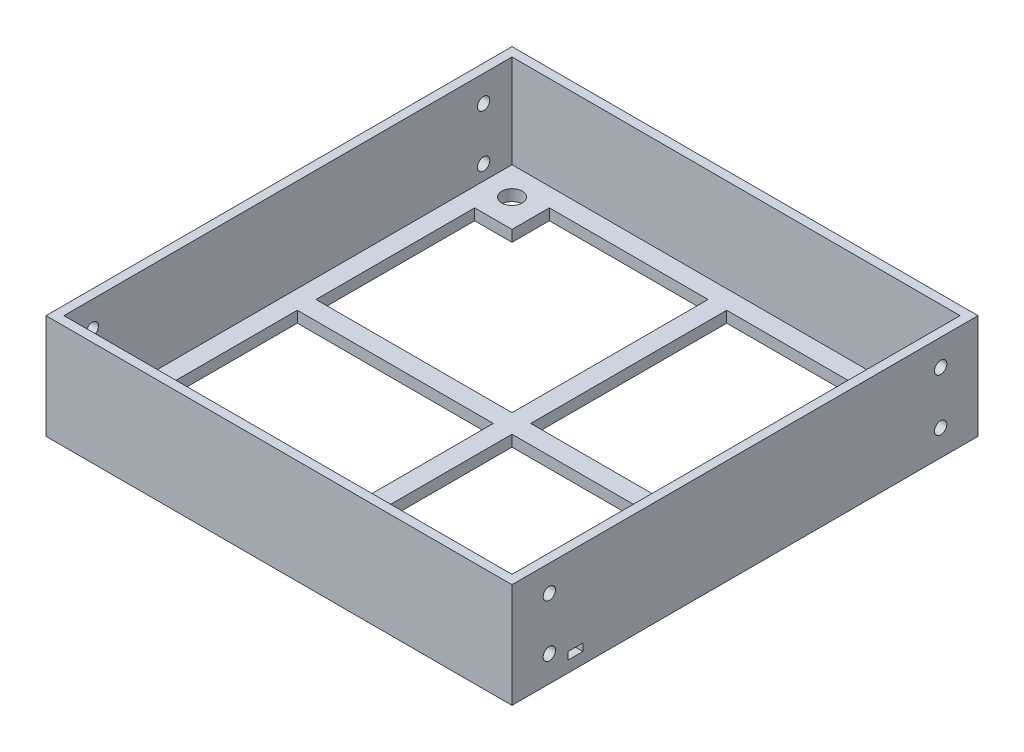
from build123d import *

# Parameters (mm, degrees)
SKETCH1_W                      = 120
SKETCH1_H                      = 120
BOSS_EXTRUDE1_DEPTH            = 3
CUT_EXTRUDE1_REACH             = 5
CUT_EXTRUDE1_DIRECTION_2_DEPTH = 1
CUT_EXTRUDE2_REACH             = 5
SKETCH3_R                      = 2.75
SKETCH5_W                      = 124.8
SKETCH5_H                      = 124.8
SKETCH5_W_2                    = 120
SKETCH5_H_2                    = 120
BOSS_EXTRUDE2_DEPTH            = 28
SKETCH6_R                      = 1.65
CUT_EXTRUDE3_DEPTH             = 125.8
SKETCH7_W                      = 4
SKETCH7_H                      = 2
CUT_EXTRUDE4_DEPTH             = 125.8


with BuildPart() as part:
    # Sketch1 → Boss-Extrude1 (new body)
    with BuildSketch(Plane(origin=(0, 0, 0), x_dir=(1, 0, 0), z_dir=(0, 1, 0))):
        with Locations((60, 60)):
            Rectangle(SKETCH1_W, SKETCH1_H)
    extrude(amount=BOSS_EXTRUDE1_DEPTH)

    # Sketch2 → Cut-Extrude1 (cut, up to next)
    with BuildSketch(Plane(origin=(0, 3, 0), x_dir=(1, 0, 0), z_dir=(0, 1, 0)), mode=Mode.PRIVATE) as cut_extrude1_sk1:
        Polygon((15, 115), (57.5, 115), (57.5, 62.5), (5, 62.5), (5, 105), (15, 105), align=None)
    cut_extrude1_tool1 = extrude(cut_extrude1_sk1.sketch, amount=-CUT_EXTRUDE1_REACH, mode=Mode.PRIVATE) & part.part
    add(cut_extrude1_tool1.solids().sort_by_distance((32.05, 3, -87.95))[0], mode=Mode.SUBTRACT)
    # Sketch2 → Cut-Extrude1 (cut, up to next)
    with BuildSketch(Plane(origin=(0, 3, 0), x_dir=(1, 0, 0), z_dir=(0, 1, 0)), mode=Mode.PRIVATE) as cut_extrude1_sk2:
        Polygon((62.5, 5), (62.5, 57.5), (115, 57.5), (115, 15), (105, 15), (105, 5), align=None)
    cut_extrude1_tool2 = extrude(cut_extrude1_sk2.sketch, amount=-CUT_EXTRUDE1_REACH, mode=Mode.PRIVATE) & part.part
    add(cut_extrude1_tool2.solids().sort_by_distance((87.95, 3, -32.05))[0], mode=Mode.SUBTRACT)
    # Sketch2 → Cut-Extrude1 (cut, up to next)
    with BuildSketch(Plane(origin=(0, 3, 0), x_dir=(1, 0, 0), z_dir=(0, 1, 0)), mode=Mode.PRIVATE) as cut_extrude1_sk3:
        Polygon((15, 5), (57.5, 5), (57.5, 57.5), (5, 57.5), (5, 15), (15, 15), align=None)
    cut_extrude1_tool3 = extrude(cut_extrude1_sk3.sketch, amount=-CUT_EXTRUDE1_REACH, mode=Mode.PRIVATE) & part.part
    add(cut_extrude1_tool3.solids().sort_by_distance((32.05, 3, -32.05))[0], mode=Mode.SUBTRACT)
    # Sketch2 → Cut-Extrude1 (cut, up to next)
    with BuildSketch(Plane(origin=(0, 3, 0), x_dir=(1, 0, 0), z_dir=(0, 1, 0)), mode=Mode.PRIVATE) as cut_extrude1_sk4:
        Polygon((115, 62.5), (62.5, 62.5), (62.5, 115), (105, 115), (105, 105), (115, 105), align=None)
    cut_extrude1_tool4 = extrude(cut_extrude1_sk4.sketch, amount=-CUT_EXTRUDE1_REACH, mode=Mode.PRIVATE) & part.part
    add(cut_extrude1_tool4.solids().sort_by_distance((87.95, 3, -87.95))[0], mode=Mode.SUBTRACT)

    # Sketch2 → Cut-Extrude1 direction 2 (cut)
    with BuildSketch(Plane(origin=(0, 3, 0), x_dir=(1, 0, 0), z_dir=(0, 1, 0))):
        Polygon((15, 115), (57.5, 115), (57.5, 62.5), (5, 62.5), (5, 105), (15, 105), align=None)
        Polygon((62.5, 5), (62.5, 57.5), (115, 57.5), (115, 15), (105, 15), (105, 5), align=None)
        Polygon((15, 5), (57.5, 5), (57.5, 57.5), (5, 57.5), (5, 15), (15, 15), align=None)
        Polygon((115, 62.5), (62.5, 62.5), (62.5, 115), (105, 115), (105, 105), (115, 105), align=None)
    extrude(amount=CUT_EXTRUDE1_DIRECTION_2_DEPTH, mode=Mode.SUBTRACT)

    # Sketch3 → Cut-Extrude2 (cut, up to next)
    with BuildSketch(Plane(origin=(0, 3, 0), x_dir=(1, 0, 0), z_dir=(0, 1, 0)), mode=Mode.PRIVATE) as cut_extrude2_sk1:
        with Locations((7.5, 112.5)):
            Circle(SKETCH3_R)
    cut_extrude2_tool1 = extrude(cut_extrude2_sk1.sketch, amount=-CUT_EXTRUDE2_REACH, mode=Mode.PRIVATE) & part.part
    add(cut_extrude2_tool1.solids().sort_by_distance((7.5, 3, -112.5))[0], mode=Mode.SUBTRACT)
    # Sketch3 → Cut-Extrude2 (cut, up to next)
    with BuildSketch(Plane(origin=(0, 3, 0), x_dir=(1, 0, 0), z_dir=(0, 1, 0)), mode=Mode.PRIVATE) as cut_extrude2_sk2:
        with Locations((112.5, 112.5)):
            Circle(SKETCH3_R)
    cut_extrude2_tool2 = extrude(cut_extrude2_sk2.sketch, amount=-CUT_EXTRUDE2_REACH, mode=Mode.PRIVATE) & part.part
    add(cut_extrude2_tool2.solids().sort_by_distance((112.5, 3, -112.5))[0], mode=Mode.SUBTRACT)
    # Sketch3 → Cut-Extrude2 (cut, up to next)
    with BuildSketch(Plane(origin=(0, 3, 0), x_dir=(1, 0, 0), z_dir=(0, 1, 0)), mode=Mode.PRIVATE) as cut_extrude2_sk3:
        with Locations((112.5, 7.5)):
            Circle(SKETCH3_R)
    cut_extrude2_tool3 = extrude(cut_extrude2_sk3.sketch, amount=-CUT_EXTRUDE2_REACH, mode=Mode.PRIVATE) & part.part
    add(cut_extrude2_tool3.solids().sort_by_distance((112.5, 3, -7.5))[0], mode=Mode.SUBTRACT)
    # Sketch3 → Cut-Extrude2 (cut, up to next)
    with BuildSketch(Plane(origin=(0, 3, 0), x_dir=(1, 0, 0), z_dir=(0, 1, 0)), mode=Mode.PRIVATE) as cut_extrude2_sk4:
        with Locations((7.5, 7.5)):
            Circle(SKETCH3_R)
    cut_extrude2_tool4 = extrude(cut_extrude2_sk4.sketch, amount=-CUT_EXTRUDE2_REACH, mode=Mode.PRIVATE) & part.part
    add(cut_extrude2_tool4.solids().sort_by_distance((7.5, 3, -7.5))[0], mode=Mode.SUBTRACT)

    # Sketch5 → Boss-Extrude2 (add)
    with BuildSketch(Plane(origin=(0, 0, 0), x_dir=(1, 0, 0), z_dir=(0, 1, 0))):
        with Locations((60, 60)):
            Rectangle(SKETCH5_W, SKETCH5_H)
        with Locations((60, 60)):
            Rectangle(SKETCH5_W_2, SKETCH5_H_2, mode=Mode.SUBTRACT)
    extrude(amount=BOSS_EXTRUDE2_DEPTH)

    # Sketch6 → Cut-Extrude3 (cut, through all)
    with BuildSketch(Plane.ZY.offset(2.4)):
        with Locations((-112.4, 21)):
            Circle(SKETCH6_R)
        with Locations((-112.4, 7)):
            Circle(SKETCH6_R)
        with Locations((-7.6, 7)):
            Circle(SKETCH6_R)
        with Locations((-7.6, 21)):
            Circle(SKETCH6_R)
    extrude(amount=-CUT_EXTRUDE3_DEPTH, mode=Mode.SUBTRACT)

    # Sketch7 → Cut-Extrude4 (cut, through all)
    with BuildSketch(Plane.ZY.offset(2.4)):
        with Locations((-14.6, 4)):
            Rectangle(SKETCH7_W, SKETCH7_H)
    extrude(amount=-CUT_EXTRUDE4_DEPTH, mode=Mode.SUBTRACT)


solid = part.part
